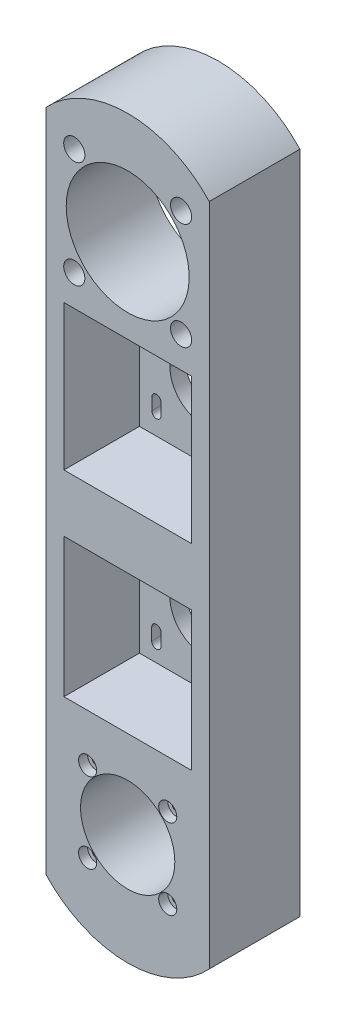
from build123d import *

# Parameters (mm, degrees)
SKETCH_1_W                = 54
SKETCH_1_H                = 220
EXTRUDE_1_DEPTH           = 30
SKETCH_2_W                = 42.2
SKETCH_2_H                = 48
CUT_EXTRUDE_1_DEPTH       = 25
SKETCH_3_W                = 42.2
SKETCH_3_H                = 46
CUT_EXTRUDE_2_DEPTH       = 25
CUT_EXTRUDE_3_DEPTH       = 6
CUT_EXTRUDE_13_DEPTH      = 6
SKETCH_18_W               = 32.2
SKETCH_18_H               = 32.2
CUT_EXTRUDE_9_DEPTH       = 6
SKETCH_9_R                = 15.6
SKETCH_9_R_2              = 1.6
CUT_EXTRUDE_4_DEPTH       = 25
SKETCH_16_W               = 42.7
SKETCH_16_H               = 42.7
CUT_EXTRUDE_7_DEPTH       = 2.5
SKETCH_13_R               = 20.35
SKETCH_13_R_2             = 2.1
CUT_EXTRUDE_6_DEPTH       = 28.5
EXTRUDE_3_DEPTH           = 30
SKETCH_17_R               = 1.5
CUT_EXTRUDE_8_DEPTH       = 8
SKETCH_21_R               = 3.5
CUT_EXTRUDE_11_DEPTH      = 1
CUT_EXTRUDE_11_DEPTH_BACK = 7.5
EXTRUDE_4_DEPTH           = 30
SKETCH_29_R               = 3
CUT_EXTRUDE_15_DEPTH      = 3
SKETCH_30_R               = 1.5
CUT_EXTRUDE_16_DEPTH      = 8


with BuildPart() as part:
    # 草图1 → 凸台-拉伸1 (new body)
    with BuildSketch(Plane.XY):
        Rectangle(SKETCH_1_W, SKETCH_1_H)
    extrude(amount=EXTRUDE_1_DEPTH)

    # 草图2 → 切除-拉伸1 (cut)
    with BuildSketch(Plane.XY.offset(30)):
        with Locations((0, 33)):
            Rectangle(SKETCH_2_W, SKETCH_2_H)
    extrude(amount=-CUT_EXTRUDE_1_DEPTH, mode=Mode.SUBTRACT)

    # 草图3 → 切除-拉伸2 (cut)
    with BuildSketch(Plane(origin=(0, 0, 30), x_dir=(-1, 0, 0), z_dir=(0, 0, -1))):
        with Locations((0, -33)):
            Rectangle(SKETCH_3_W, SKETCH_3_H)
    extrude(amount=CUT_EXTRUDE_2_DEPTH, mode=Mode.SUBTRACT)

    # 草图4 → 切除-拉伸3 (cut, through all)
    with BuildSketch(Plane.XY.offset(5)):
        with BuildLine():
            Line((11, 31), (11, 35))
            ThreePointArc((11, 35), (0, 46), (-11, 35))
            Line((-11, 35), (-11, 31))
            ThreePointArc((-11, 31), (0, 20), (11, 31))
        make_face()
        with BuildLine():
            Line((-14, 46.5), (-14, 50.5))
            ThreePointArc((-14, 50.5), (-15.5, 52), (-17, 50.5))
            Line((-17, 50.5), (-17, 46.5))
            ThreePointArc((-17, 46.5), (-15.5, 45), (-14, 46.5))
        make_face()
        with BuildLine():
            ThreePointArc((17, 50.5), (15.5, 52), (14, 50.5))
            Line((14, 50.5), (14, 46.5))
            ThreePointArc((14, 46.5), (15.5, 45), (17, 46.5))
            Line((17, 46.5), (17, 50.5))
        make_face()
        with BuildLine():
            Line((14, 19.5), (14, 15.5))
            ThreePointArc((14, 15.5), (15.5, 14), (17, 15.5))
            Line((17, 15.5), (17, 19.5))
            ThreePointArc((17, 19.5), (15.5, 21), (14, 19.5))
        make_face()
        with BuildLine():
            ThreePointArc((-17, 15.5), (-15.5, 14), (-14, 15.5))
            Line((-14, 15.5), (-14, 19.5))
            ThreePointArc((-14, 19.5), (-15.5, 21), (-17, 19.5))
            Line((-17, 19.5), (-17, 15.5))
        make_face()
    extrude(amount=-CUT_EXTRUDE_3_DEPTH, mode=Mode.SUBTRACT)

    # 草图26 → 切除-拉伸13 (cut, through all)
    with BuildSketch(Plane.XY.offset(5)):
        with BuildLine():
            Line((11, -31), (11, -35))
            ThreePointArc((11, -35), (0, -46), (-11, -35))
            Line((-11, -35), (-11, -31))
            ThreePointArc((-11, -31), (0, -20), (11, -31))
        make_face()
        with BuildLine():
            Line((-13.95, -15.5), (-13.95, -19.5))
            ThreePointArc((-13.95, -19.5), (-15.5, -21.05), (-17.05, -19.5))
            Line((-17.05, -19.5), (-17.05, -15.5))
            ThreePointArc((-17.05, -15.5), (-15.5, -13.95), (-13.95, -15.5))
        make_face()
        with BuildLine():
            Line((-13.95, -50.5), (-13.95, -46.5))
            ThreePointArc((-13.95, -46.5), (-15.5, -44.95), (-17.05, -46.5))
            Line((-17.05, -46.5), (-17.05, -50.5))
            ThreePointArc((-17.05, -50.5), (-15.5, -52.05), (-13.95, -50.5))
        make_face()
        with BuildLine():
            Line((13.95, -50.5), (13.95, -46.5))
            ThreePointArc((13.95, -46.5), (15.5, -44.95), (17.05, -46.5))
            Line((17.05, -46.5), (17.05, -50.5))
            ThreePointArc((17.05, -50.5), (15.5, -52.05), (13.95, -50.5))
        make_face()
        with BuildLine():
            Line((13.95, -15.5), (13.95, -19.5))
            ThreePointArc((13.95, -19.5), (15.5, -21.05), (17.05, -19.5))
            Line((17.05, -19.5), (17.05, -15.5))
            ThreePointArc((17.05, -15.5), (15.5, -13.95), (13.95, -15.5))
        make_face()
    extrude(amount=-CUT_EXTRUDE_13_DEPTH, mode=Mode.SUBTRACT)

    # 草图18 → 切除-拉伸9 (cut)
    with BuildSketch(Plane.XY):
        with Locations((0, -85)):
            Rectangle(SKETCH_18_W, SKETCH_18_H)
    extrude(amount=CUT_EXTRUDE_9_DEPTH, mode=Mode.SUBTRACT)

    # 草图9 → 切除-拉伸4 (cut, through all)
    with BuildSketch(Plane.XY.offset(6)):
        with Locations((0, -85)):
            Circle(SKETCH_9_R)
        with Locations((-13.258252147, -71.741747853)):
            Circle(SKETCH_9_R_2)
        with Locations((13.258252147, -71.741747853)):
            Circle(SKETCH_9_R_2)
        with Locations((13.258252147, -98.258252147)):
            Circle(SKETCH_9_R_2)
        with Locations((-13.258252147, -98.258252147)):
            Circle(SKETCH_9_R_2)
    extrude(amount=CUT_EXTRUDE_4_DEPTH, mode=Mode.SUBTRACT)

    # 草图16 → 切除-拉伸7 (cut)
    with BuildSketch(Plane.XY):
        with Locations((0, 85)):
            Rectangle(SKETCH_16_W, SKETCH_16_H)
    extrude(amount=CUT_EXTRUDE_7_DEPTH, mode=Mode.SUBTRACT)

    # 草图13 → 切除-拉伸6 (cut, through all)
    with BuildSketch(Plane(origin=(0, 0, 2.5), x_dir=(-1, 0, 0), z_dir=(0, 0, -1))):
        with Locations((0, 85)):
            Circle(SKETCH_13_R)
        with Locations((-17.67766953, 102.67766953)):
            Circle(SKETCH_13_R_2)
        with Locations((17.67766953, 102.67766953)):
            Circle(SKETCH_13_R_2)
        with Locations((17.67766953, 67.32233047)):
            Circle(SKETCH_13_R_2)
        with Locations((-17.67766953, 67.32233047)):
            Circle(SKETCH_13_R_2)
    extrude(amount=-CUT_EXTRUDE_6_DEPTH, mode=Mode.SUBTRACT)

    # 草图15 → 凸台-拉伸3 (add)
    with BuildSketch(Plane(origin=(0, 0, 0), x_dir=(-1, 0, 0), z_dir=(0, 0, -1))):
        with BuildLine():
            Line((-27, 110), (27, 110))
            ThreePointArc((27, 110), (0, 121.796738986), (-27, 110))
        make_face()
    extrude(amount=-EXTRUDE_3_DEPTH)

    # 草图17 → 切除-拉伸8 (cut)
    with BuildSketch(Plane(origin=(0, 0, 0), x_dir=(-1, 0, 0), z_dir=(0, 0, -1))):
        with Locations((-24, 100)):
            Circle(SKETCH_17_R)
        with Locations((24, 100)):
            Circle(SKETCH_17_R)
        with Locations((24, 66)):
            Circle(SKETCH_17_R)
        with Locations((-24, 66)):
            Circle(SKETCH_17_R)
    extrude(amount=-CUT_EXTRUDE_8_DEPTH, mode=Mode.SUBTRACT)

    # 草图21 → 切除-拉伸11 (cut, two sides)
    with BuildSketch(Plane.XY.offset(30)) as cut_extrude_11_sk:
        with Locations((-17.67766953, 102.67766953)):
            Circle(SKETCH_21_R)
        with Locations((17.67766953, 102.67766953)):
            Circle(SKETCH_21_R)
        with Locations((17.67766953, 67.32233047)):
            Circle(SKETCH_21_R)
        with Locations((-17.67766953, 67.32233047)):
            Circle(SKETCH_21_R)
    extrude(amount=CUT_EXTRUDE_11_DEPTH, mode=Mode.SUBTRACT)
    extrude(cut_extrude_11_sk.sketch, amount=-CUT_EXTRUDE_11_DEPTH_BACK, mode=Mode.SUBTRACT)

    # 草图28 → 凸台-拉伸4 (add)
    with BuildSketch(Plane.XY.offset(30)):
        with BuildLine():
            Line((-27, -110), (27, -110))
            ThreePointArc((27, -110), (0, -121.795200461), (-27, -110))
        make_face()
    extrude(amount=-EXTRUDE_4_DEPTH)

    # 草图29 → 切除-拉伸15 (cut)
    with BuildSketch(Plane.XY.offset(30)):
        with Locations((-13.258252147, -71.741747853)):
            Circle(SKETCH_29_R)
        with Locations((13.258252147, -71.741747853)):
            Circle(SKETCH_29_R)
        with Locations((13.258252147, -98.258252147)):
            Circle(SKETCH_29_R)
        with Locations((-13.258252147, -98.258252147)):
            Circle(SKETCH_29_R)
    extrude(amount=-CUT_EXTRUDE_15_DEPTH, mode=Mode.SUBTRACT)

    # 草图30 → 切除-拉伸16 (cut)
    with BuildSketch(Plane(origin=(0, 0, 0), x_dir=(-1, 0, 0), z_dir=(0, 0, -1))):
        with Locations((-24, -100)):
            Circle(SKETCH_30_R)
        with Locations((-24, -66)):
            Circle(SKETCH_30_R)
        with Locations((24, -66)):
            Circle(SKETCH_30_R)
        with Locations((24, -100)):
            Circle(SKETCH_30_R)
    extrude(amount=-CUT_EXTRUDE_16_DEPTH, mode=Mode.SUBTRACT)


solid = part.part
